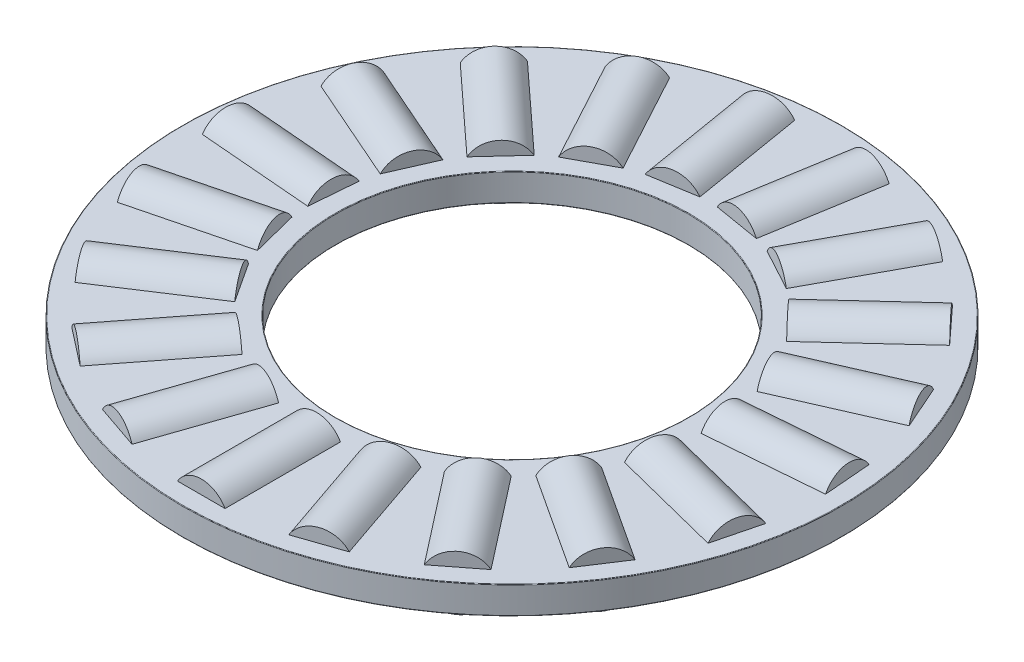
from build123d import *

# Parameters (mm, degrees)
SKETCH1_W         = 5.53085
SKETCH1_H         = 0.9921875
SKETCH3_W         = 4.1671875
SKETCH3_H         = 0.9921875
SKETCH2_W         = 4.1671875
SKETCH2_H         = 0.9921875
CIRPATTERN1_COUNT = 19
CIRPATTERN1_ANGLE = 341.052631579
CIRPATTERN2_COUNT = 19
FILLET2_R         = 0.01984375


with BuildPart() as part:
    # Sketch1 → Revolve1 (revolve)
    with BuildSketch(Plane(origin=(0, 0, 0), x_dir=(0, 0, -1), z_dir=(1, 0, 0)), mode=Mode.PRIVATE) as revolve1_sk:
        with Locations((-9.140825, 0)):
            Rectangle(SKETCH1_W, SKETCH1_H)
    revolve(revolve1_sk.sketch.rotate(Axis((0, -0.9921875, 0), (0, 1, 0)), 180), axis=Axis((0, -0.9921875, 0), (0, 1, 0)))

    # Sketch3 → Cut-Revolve1 (revolve, cut)
    with BuildSketch(Plane(origin=(0, 0, 0), x_dir=(0, 0, -1), z_dir=(1, 0, 0))):
        with Locations((-9.140825, 0.49609375)):
            Rectangle(SKETCH3_W, SKETCH3_H)
    cut_revolve1 = revolve(axis=Axis((0, 0, 11.22441875), (0, 0, -1)), mode=Mode.SUBTRACT)

    # CirPattern2: Cut-Revolve1 ×19 about axis
    cirpattern2_axis = Axis((0, 0, 0), (0, 1, 0))
    for i in range(1, CIRPATTERN2_COUNT):
        add(cut_revolve1.rotate(cirpattern2_axis, i * 360 / CIRPATTERN2_COUNT), mode=Mode.SUBTRACT)

    # Fillet2
    fillet2_edges = [part.edges().sort_by_distance(p)[0] for p in [
        (0, 0.49609375, 11.90625),
        (0, 0.49609375, 6.3754),
        (0, -0.49609375, 6.3754),
        (0, -0.49609375, 11.90625),
    ]]
    fillet(fillet2_edges, radius=FILLET2_R)


with BuildPart() as body_2:
    # Sketch2 → Revolve2 (revolve)
    with BuildSketch(Plane(origin=(0, 0, 0), x_dir=(0, 0, -1), z_dir=(1, 0, 0)), mode=Mode.PRIVATE) as revolve2_sk:
        with Locations((-9.140825, 0.49609375)):
            Rectangle(SKETCH2_W, SKETCH2_H)
    revolve(revolve2_sk.sketch.rotate(Axis((0, 0, 11.22441875), (0, 0, -1)), 90), axis=Axis((0, 0, 11.22441875), (0, 0, -1)))


with BuildPart() as cirpattern1_1:
    # CirPattern1: pattern copy
    add(body_2.part.rotate(Axis((0, 0.9921875, 0), (0, -1, 0)), 1 * CIRPATTERN1_ANGLE / (CIRPATTERN1_COUNT - 1)))


with BuildPart() as cirpattern1_2:
    # CirPattern1: pattern copy
    add(body_2.part.rotate(Axis((0, 0.9921875, 0), (0, -1, 0)), 2 * CIRPATTERN1_ANGLE / (CIRPATTERN1_COUNT - 1)))


with BuildPart() as cirpattern1_3:
    # CirPattern1: pattern copy
    add(body_2.part.rotate(Axis((0, 0.9921875, 0), (0, -1, 0)), 3 * CIRPATTERN1_ANGLE / (CIRPATTERN1_COUNT - 1)))


with BuildPart() as cirpattern1_4:
    # CirPattern1: pattern copy
    add(body_2.part.rotate(Axis((0, 0.9921875, 0), (0, -1, 0)), 4 * CIRPATTERN1_ANGLE / (CIRPATTERN1_COUNT - 1)))


with BuildPart() as cirpattern1_5:
    # CirPattern1: pattern copy
    add(body_2.part.rotate(Axis((0, 0.9921875, 0), (0, -1, 0)), 5 * CIRPATTERN1_ANGLE / (CIRPATTERN1_COUNT - 1)))


with BuildPart() as cirpattern1_6:
    # CirPattern1: pattern copy
    add(body_2.part.rotate(Axis((0, 0.9921875, 0), (0, -1, 0)), 6 * CIRPATTERN1_ANGLE / (CIRPATTERN1_COUNT - 1)))


with BuildPart() as cirpattern1_7:
    # CirPattern1: pattern copy
    add(body_2.part.rotate(Axis((0, 0.9921875, 0), (0, -1, 0)), 7 * CIRPATTERN1_ANGLE / (CIRPATTERN1_COUNT - 1)))


with BuildPart() as cirpattern1_8:
    # CirPattern1: pattern copy
    add(body_2.part.rotate(Axis((0, 0.9921875, 0), (0, -1, 0)), 8 * CIRPATTERN1_ANGLE / (CIRPATTERN1_COUNT - 1)))


with BuildPart() as cirpattern1_9:
    # CirPattern1: pattern copy
    add(body_2.part.rotate(Axis((0, 0.9921875, 0), (0, -1, 0)), 9 * CIRPATTERN1_ANGLE / (CIRPATTERN1_COUNT - 1)))


with BuildPart() as cirpattern1_10:
    # CirPattern1: pattern copy
    add(body_2.part.rotate(Axis((0, 0.9921875, 0), (0, -1, 0)), 10 * CIRPATTERN1_ANGLE / (CIRPATTERN1_COUNT - 1)))


with BuildPart() as cirpattern1_11:
    # CirPattern1: pattern copy
    add(body_2.part.rotate(Axis((0, 0.9921875, 0), (0, -1, 0)), 11 * CIRPATTERN1_ANGLE / (CIRPATTERN1_COUNT - 1)))


with BuildPart() as cirpattern1_12:
    # CirPattern1: pattern copy
    add(body_2.part.rotate(Axis((0, 0.9921875, 0), (0, -1, 0)), 12 * CIRPATTERN1_ANGLE / (CIRPATTERN1_COUNT - 1)))


with BuildPart() as cirpattern1_13:
    # CirPattern1: pattern copy
    add(body_2.part.rotate(Axis((0, 0.9921875, 0), (0, -1, 0)), 13 * CIRPATTERN1_ANGLE / (CIRPATTERN1_COUNT - 1)))


with BuildPart() as cirpattern1_14:
    # CirPattern1: pattern copy
    add(body_2.part.rotate(Axis((0, 0.9921875, 0), (0, -1, 0)), 14 * CIRPATTERN1_ANGLE / (CIRPATTERN1_COUNT - 1)))


with BuildPart() as cirpattern1_15:
    # CirPattern1: pattern copy
    add(body_2.part.rotate(Axis((0, 0.9921875, 0), (0, -1, 0)), 15 * CIRPATTERN1_ANGLE / (CIRPATTERN1_COUNT - 1)))


with BuildPart() as cirpattern1_16:
    # CirPattern1: pattern copy
    add(body_2.part.rotate(Axis((0, 0.9921875, 0), (0, -1, 0)), 16 * CIRPATTERN1_ANGLE / (CIRPATTERN1_COUNT - 1)))


with BuildPart() as cirpattern1_17:
    # CirPattern1: pattern copy
    add(body_2.part.rotate(Axis((0, 0.9921875, 0), (0, -1, 0)), 17 * CIRPATTERN1_ANGLE / (CIRPATTERN1_COUNT - 1)))


with BuildPart() as cirpattern1_18:
    # CirPattern1: pattern copy
    add(body_2.part.rotate(Axis((0, 0.9921875, 0), (0, -1, 0)), 18 * CIRPATTERN1_ANGLE / (CIRPATTERN1_COUNT - 1)))


solid = Compound([part.part, body_2.part, cirpattern1_1.part, cirpattern1_2.part, cirpattern1_3.part, cirpattern1_4.part, cirpattern1_5.part, cirpattern1_6.part, cirpattern1_7.part, cirpattern1_8.part, cirpattern1_9.part, cirpattern1_10.part, cirpattern1_11.part, cirpattern1_12.part, cirpattern1_13.part, cirpattern1_14.part, cirpattern1_15.part, cirpattern1_16.part, cirpattern1_17.part, cirpattern1_18.part])
